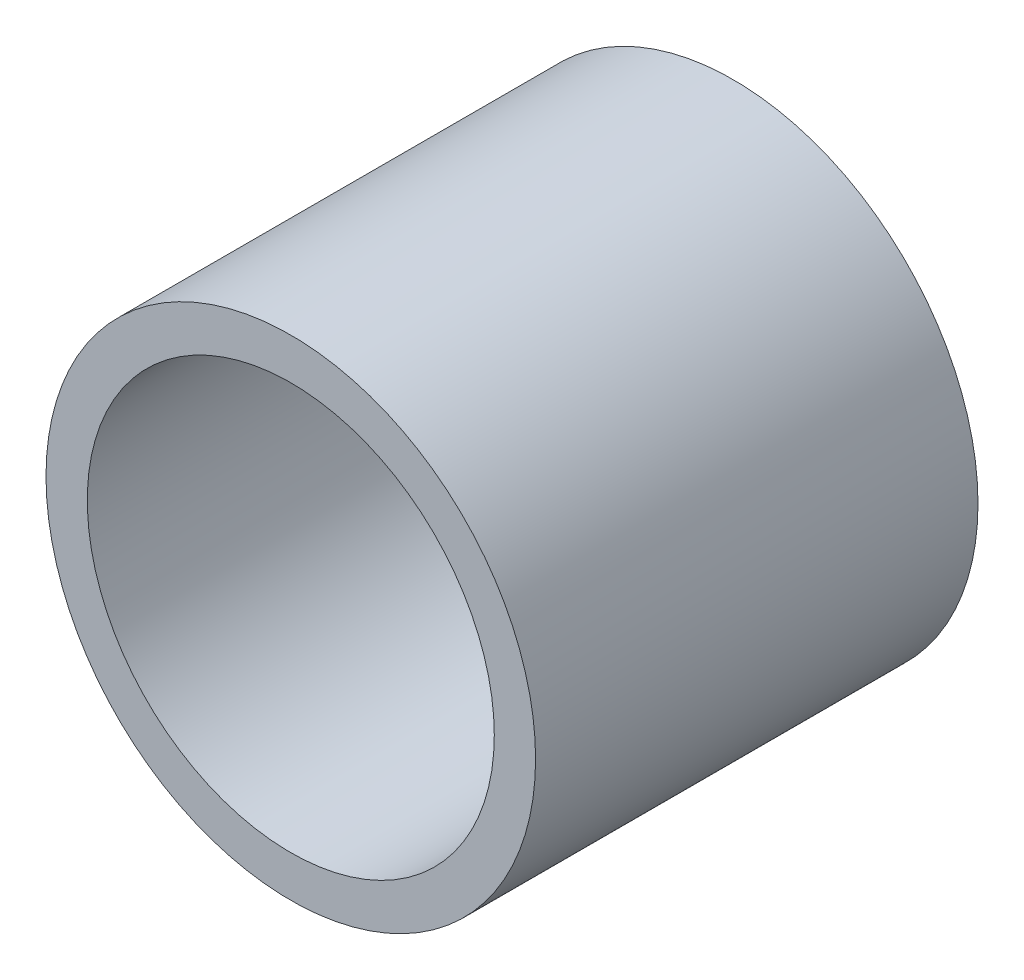
from build123d import *

# Parameters (mm, degrees)
SKETCH1_R           = 21.082
SKETCH1_R_2         = 17.526
EXTRUDE_THIN1_DEPTH = 19.05


with BuildPart() as part:
    # Sketch1 → Extrude-Thin1 (new body, symmetric)
    with BuildSketch(Plane.XY):
        Circle(SKETCH1_R)
        Circle(SKETCH1_R_2, mode=Mode.SUBTRACT)
    extrude(amount=EXTRUDE_THIN1_DEPTH, both=True)


solid = part.part
